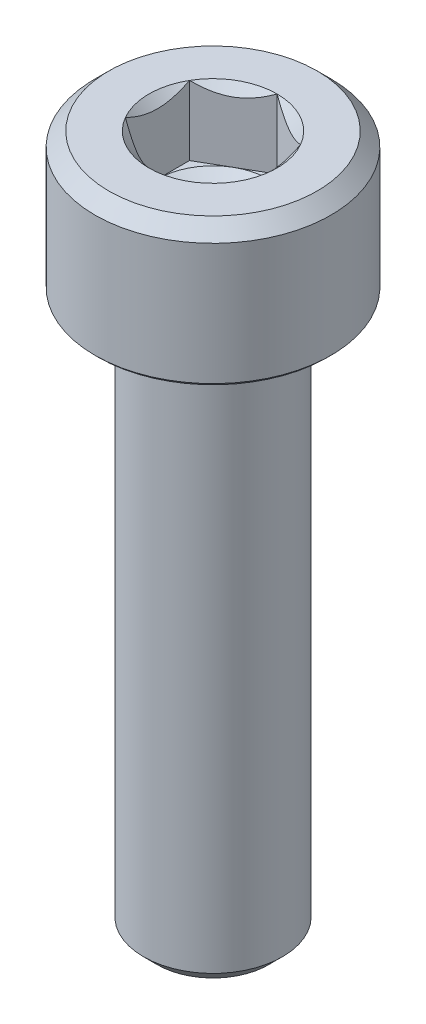
from build123d import *

# Parameters (mm, degrees)
CUT_EXTRUDE1_DEPTH = 2.5


with BuildPart() as part:
    # Sketch1 → Revolve1 (revolve)
    with BuildSketch(Plane.XY):
        Polygon((0, 1.345299462), (2, 2.5), (2, 4.690598923), (2.309401077, 5), (3.75, 5), (4.25, 4.5), (4.25, 0.125), (4.125, 0), (2.55, 0), (2.5, -0.6), (2.5, -19.5095), (2.0095, -20), (0, -20), align=None)
    revolve(axis=Axis((0, -20, 0), (0, 1, 0)))

    # Sketch2 → Cut-Extrude1 (cut)
    with BuildSketch(Plane(origin=(0, 5, 0), x_dir=(1, 0, 0), z_dir=(0, 1, 0))):
        Polygon((-2, -1.154700538), (0, -2.309401077), (2, -1.154700538), (2, 1.154700538), (0, 2.309401077), (-2, 1.154700538), align=None)
    extrude(amount=-CUT_EXTRUDE1_DEPTH, mode=Mode.SUBTRACT)


solid = part.part
